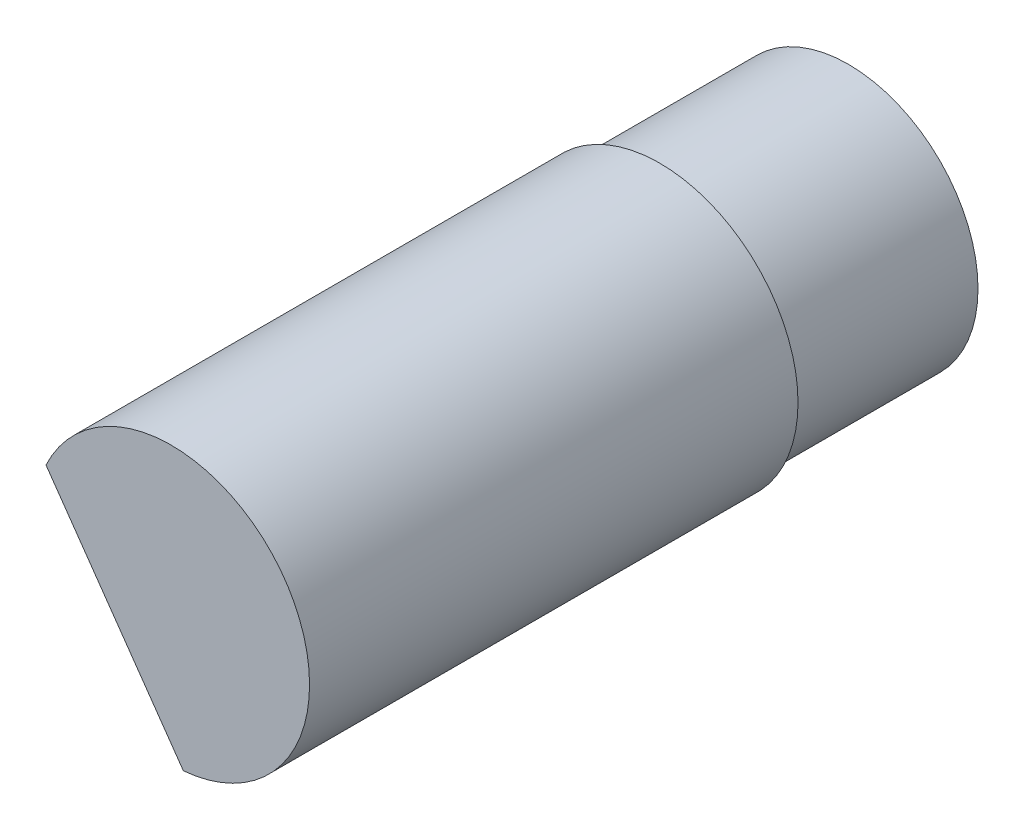
from build123d import *

# Parameters (mm, degrees)
SKETCH1_R           = 5.926666667
BOSS_EXTRUDE1_DEPTH = 8.636
SKETCH2_R           = 6.326666667
BOSS_EXTRUDE2_DEPTH = 18.965333333
BOSS_EXTRUDE3_DEPTH = 3.386666667


with BuildPart() as part:
    # Sketch1 → Boss-Extrude1 (new body)
    with BuildSketch(Plane.XY):
        with Locations((110.576144023, 32.69693519)):
            Circle(SKETCH1_R)
    extrude(amount=BOSS_EXTRUDE1_DEPTH)

    # Sketch2 → Boss-Extrude2 (add)
    with BuildSketch(Plane.XY.offset(8.636)):
        with Locations((110.576144023, 32.69693519)):
            Circle(SKETCH2_R)
    extrude(amount=BOSS_EXTRUDE2_DEPTH)

    # Sketch3 → Boss-Extrude3 (add)
    with BuildSketch(Plane.XY.offset(27.601333333)):
        with BuildLine():
            Line((104.842236757, 35.37070006), (107.984893057, 30.88252173))
            Line((107.984893057, 30.88252173), (111.127549356, 26.3943434))
            ThreePointArc((111.127549356, 26.3943434), (115.240651974, 28.422701143), (116.90281069, 32.69693519))
            ThreePointArc((116.90281069, 32.69693519), (111.945485314, 38.873634595), (104.842236757, 35.37070006))
        make_face()
    extrude(amount=BOSS_EXTRUDE3_DEPTH)


solid = part.part
